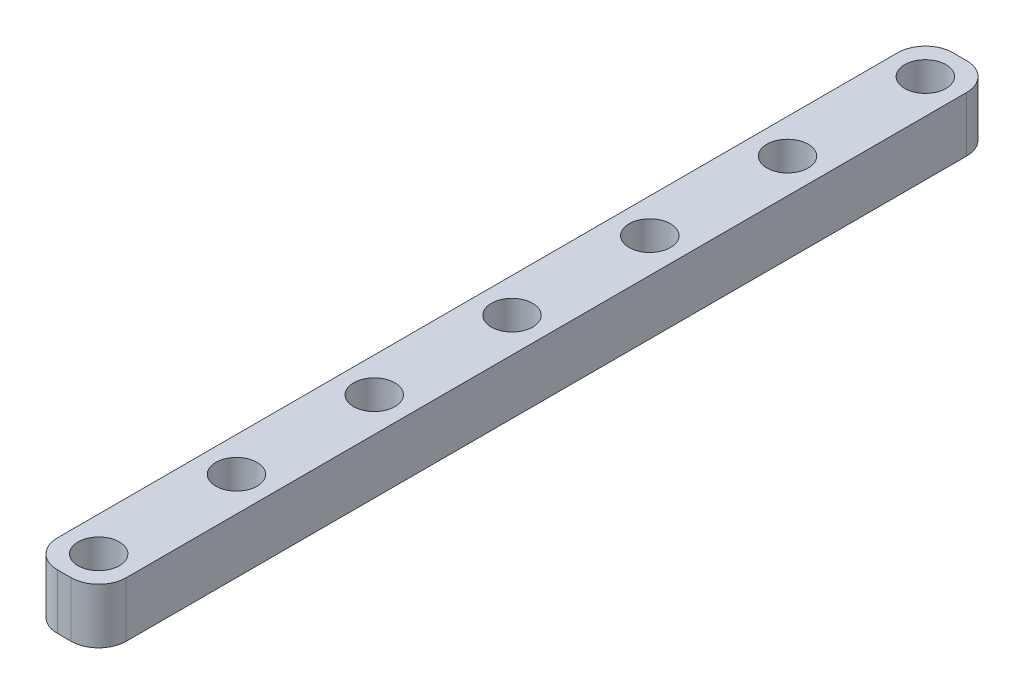
from build123d import *

# Parameters (mm, degrees)
SKETCH2_W           = 5
SKETCH2_H           = 65
BOSS_EXTRUDE1_DEPTH = 4
SKETCH3_R           = 1.5
CUT_EXTRUDE1_DEPTH  = 4
FILLET2_R           = 2


with BuildPart() as part:
    # Sketch2 → Boss-Extrude1 (new body)
    with BuildSketch(Plane(origin=(0, 0, 0), x_dir=(1, 0, 0), z_dir=(0, 1, 0))):
        with Locations((-2.5, 32.5)):
            Rectangle(SKETCH2_W, SKETCH2_H)
    extrude(amount=BOSS_EXTRUDE1_DEPTH)

    # Sketch3 → Cut-Extrude1 (cut)
    with BuildSketch(Plane(origin=(0, 4, 0), x_dir=(1, 0, 0), z_dir=(0, 1, 0))):
        with Locations((-2.5, 32.5)):
            Circle(SKETCH3_R)
        with Locations((-2.5, 22.5)):
            Circle(SKETCH3_R)
        with Locations((-2.5, 12.5)):
            Circle(SKETCH3_R)
        with Locations((-2.5, 2.5)):
            Circle(SKETCH3_R)
        with Locations((-2.5, 42.5)):
            Circle(SKETCH3_R)
        with Locations((-2.5, 52.5)):
            Circle(SKETCH3_R)
        with Locations((-2.5, 62.5)):
            Circle(SKETCH3_R)
    extrude(amount=-CUT_EXTRUDE1_DEPTH, mode=Mode.SUBTRACT)

    # Fillet2
    fillet2_edges = [part.edges().sort_by_distance(p)[0] for p in [
        (0, 2, 0),
        (0, 2, -65),
        (-5, 2, -65),
        (-5, 2, 0),
    ]]
    fillet(fillet2_edges, radius=FILLET2_R)


solid = part.part
